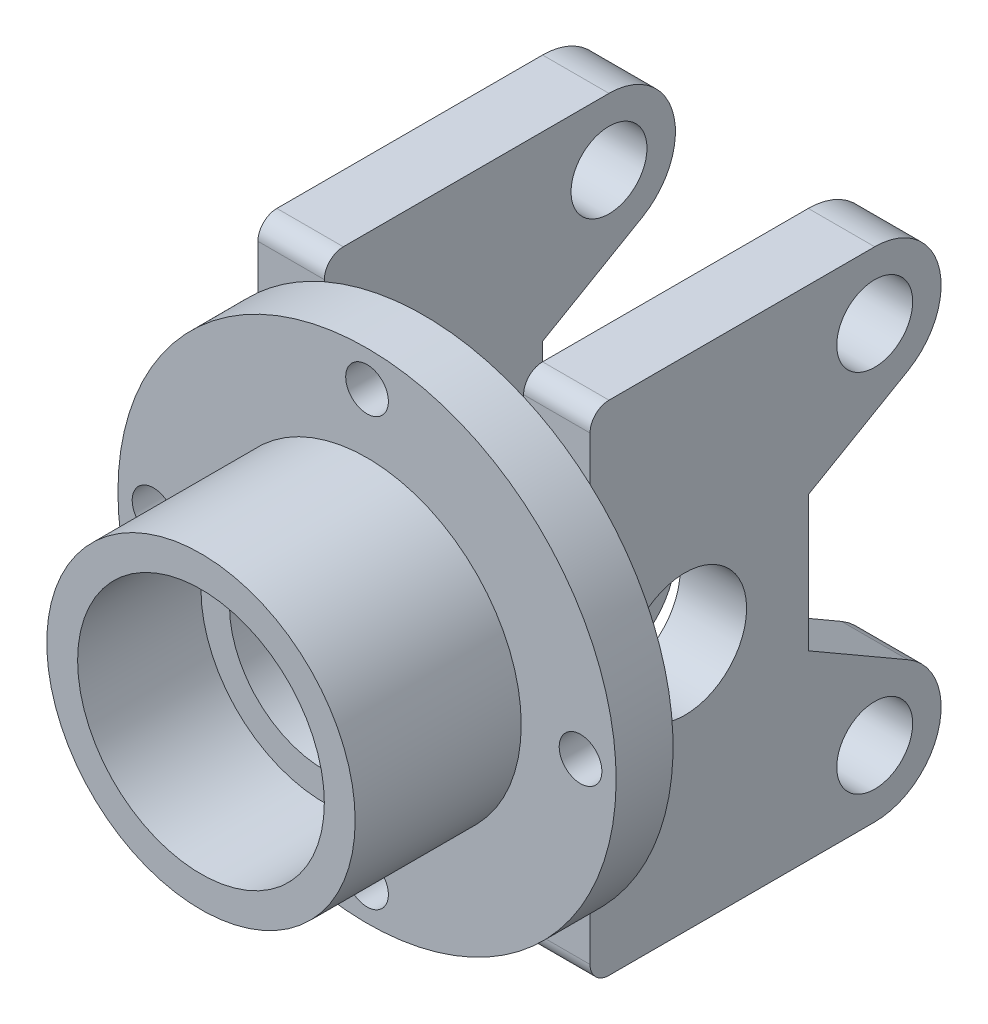
from build123d import *

# Parameters (mm, degrees)
SKETCH_1_R               = 32.5
EXTRUDE_1_DEPTH          = 35
SKETCH_2_R               = 52.5
EXTRUDE_2_DEPTH          = 12
EXTRUDE_3_DEPTH          = 35
CUT_EXTRUDE_2_DEPTH      = 21
SKETCH_7_R               = 8
SKETCH_7_R_2             = 13
CUT_EXTRUDE_3_DEPTH      = 88.5
SKETCH_8_R               = 4.5
CUT_EXTRUDE_4_DEPTH      = 48
PATTERN_CIRCULAR_1_COUNT = 4
SKETCH_9_R               = 20
CUT_EXTRUDE_5_DEPTH      = 21
SKETCH_10_R              = 26
CUT_EXTRUDE_6_DEPTH      = 27


with BuildPart() as part:
    # 草图1 → 凸台-拉伸1 (new body)
    with BuildSketch(Plane.XY):
        Circle(SKETCH_1_R)
    extrude(amount=-EXTRUDE_1_DEPTH)

    # 草图2 → 凸台-拉伸2 (add)
    with BuildSketch(Plane(origin=(0, 0, -35), x_dir=(-1, 0, 0), z_dir=(0, 0, -1))):
        Circle(SKETCH_2_R)
    extrude(amount=EXTRUDE_2_DEPTH)

    # 草图4 → 凸台-拉伸3 (add, symmetric)
    with BuildSketch(Plane(origin=(0, 0, 0), x_dir=(0, 0, -1), z_dir=(1, 0, 0))):
        with BuildLine():
            Line((51, 52.5), (107, 52.5))
            ThreePointArc((107, 52.5), (120.522961568, 42.123466631), (114, 26.375644347))
            Line((114, 26.375644347), (93, 14.251288694))
            Line((93, 14.251288694), (93, -14.251288694))
            Line((93, -14.251288694), (114, -26.375644347))
            ThreePointArc((114, -26.375644347), (120.522961568, -42.123466631), (107, -52.5))
            Line((107, -52.5), (51, -52.5))
            ThreePointArc((51, -52.5), (48.171572875, -51.328427125), (47, -48.5))
            Line((47, -48.5), (47, 48.5))
            ThreePointArc((47, 48.5), (48.171572875, 51.328427125), (51, 52.5))
        make_face()
    extrude(amount=EXTRUDE_3_DEPTH, both=True)

    # 草图6 → 切除-拉伸2 (cut, symmetric)
    with BuildSketch(Plane(origin=(0, 0, 0), x_dir=(0, 0, -1), z_dir=(1, 0, 0))):
        with BuildLine():
            Line((107, 52.5), (51, 52.5))
            ThreePointArc((51, 52.5), (48.171572875, 51.328427125), (47, 48.5))
            Line((47, 48.5), (47, 39.131189606))
            Line((47, 39.131189606), (47, -39.131189606))
            Line((47, -39.131189606), (47, -48.5))
            ThreePointArc((47, -48.5), (48.171572875, -51.328427125), (51, -52.5))
            Line((51, -52.5), (107, -52.5))
            ThreePointArc((107, -52.5), (120.522961568, -42.123466631), (114, -26.375644347))
            Line((114, -26.375644347), (93, -14.251288694))
            Line((93, -14.251288694), (93, 14.251288694))
            Line((93, 14.251288694), (114, 26.375644347))
            ThreePointArc((114, 26.375644347), (120.522961568, 42.123466631), (107, 52.5))
        make_face()
    extrude(amount=CUT_EXTRUDE_2_DEPTH, both=True, mode=Mode.SUBTRACT)

    # 草图7 → 切除-拉伸3 (cut, through all)
    with BuildSketch(Plane(origin=(35, 0, 0), x_dir=(0, 0, -1), z_dir=(1, 0, 0))):
        with Locations((107, 38.5)):
            Circle(SKETCH_7_R)
        with Locations((107, -38.5)):
            Circle(SKETCH_7_R)
        with Locations((67, 0)):
            Circle(SKETCH_7_R_2)
    extrude(amount=-CUT_EXTRUDE_3_DEPTH, mode=Mode.SUBTRACT)

    # 草图8 → 切除-拉伸4 (cut, through all)
    with BuildSketch(Plane(origin=(0, 0, -47), x_dir=(-1, 0, 0), z_dir=(0, 0, -1))):
        with Locations((0, 45)):
            Circle(SKETCH_8_R)
    cut_extrude_4 = extrude(amount=-CUT_EXTRUDE_4_DEPTH, mode=Mode.SUBTRACT)

    # 阵列(圆周)1: 切除-拉伸4 ×4 about axis
    pattern_circular_1_axis = Axis((0, 0, 0), (0, 0, 1))
    for i in range(1, PATTERN_CIRCULAR_1_COUNT):
        add(cut_extrude_4.rotate(pattern_circular_1_axis, i * 360 / PATTERN_CIRCULAR_1_COUNT), mode=Mode.SUBTRACT)

    # 草图9 → 切除-拉伸5 (cut)
    with BuildSketch(Plane(origin=(0, 0, -47), x_dir=(-1, 0, 0), z_dir=(0, 0, -1))):
        Circle(SKETCH_9_R)
    extrude(amount=-CUT_EXTRUDE_5_DEPTH, mode=Mode.SUBTRACT)

    # 草图10 → 切除-拉伸6 (cut, through all)
    with BuildSketch(Plane(origin=(0, 0, -26), x_dir=(-1, 0, 0), z_dir=(0, 0, -1))):
        Circle(SKETCH_10_R)
    extrude(amount=-CUT_EXTRUDE_6_DEPTH, mode=Mode.SUBTRACT)


solid = part.part
